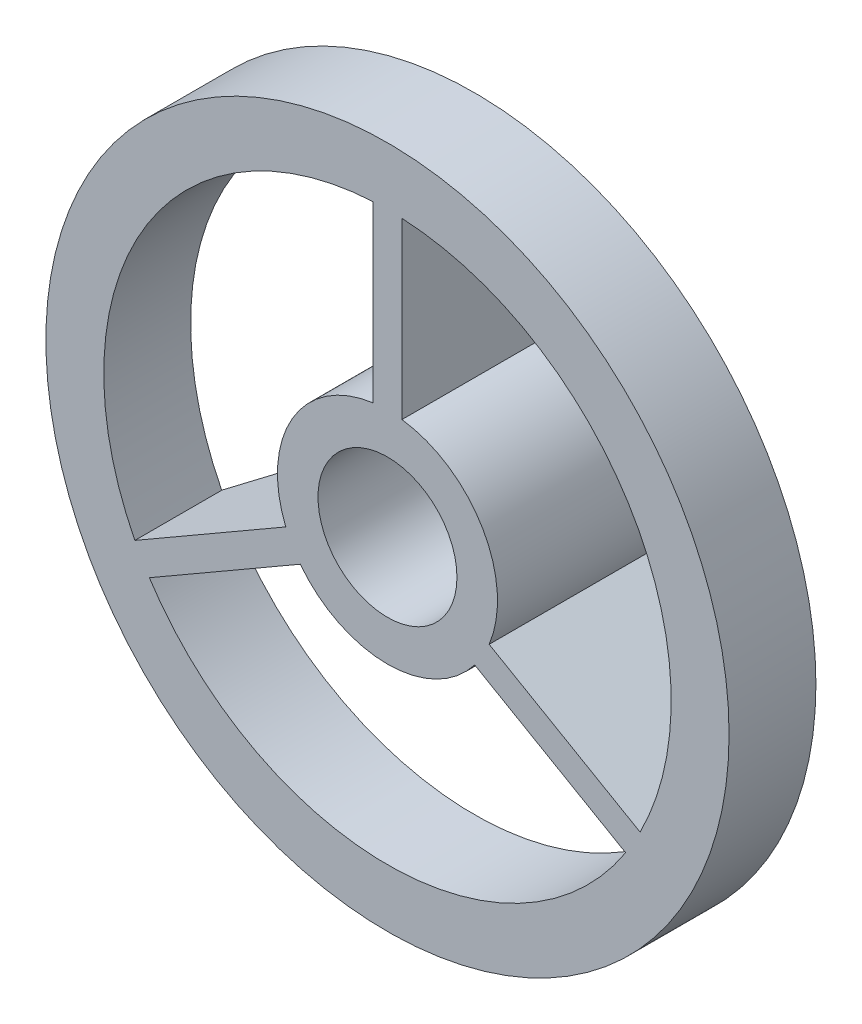
from build123d import *

# Parameters (mm, degrees)
SKETCH1_R           = 1.9
SKETCH1_R_2         = 1.2
BOSS_EXTRUDE1_DEPTH = 3.5
SKETCH2_R           = 5.9
SKETCH2_R_2         = 4.9
BOSS_EXTRUDE2_DEPTH = 1.5
BOSS_EXTRUDE3_DEPTH = 0.25
CIRPATTERN1_COUNT   = 3


with BuildPart() as part:
    # Sketch1 → Boss-Extrude1 (new body)
    with BuildSketch(Plane.XY):
        Circle(SKETCH1_R)
        Circle(SKETCH1_R_2, mode=Mode.SUBTRACT)
    extrude(amount=BOSS_EXTRUDE1_DEPTH)



with BuildPart() as body_2:
    # Sketch2 → Boss-Extrude2 (new body)
    with BuildSketch(Plane.XY.offset(3.5)):
        Circle(SKETCH2_R)
        Circle(SKETCH2_R_2, mode=Mode.SUBTRACT)
    extrude(amount=-BOSS_EXTRUDE2_DEPTH)


with BuildPart() as part_1:
    add(part.part)

    add(body_2.part)  # Boss-Extrude3 merges body 2
    # Sketch3 → Boss-Extrude3 (add, symmetric)
    with BuildSketch(Plane(origin=(0, 0, 0), x_dir=(0, 0, -1), z_dir=(1, 0, 0))):
        Polygon((0, 1.9), (-2, 4.9), (-3.5, 4.9), (-3.5, 1.9), (-3.5, 1.7), (0, 1.7), align=None)
    boss_extrude3 = extrude(amount=BOSS_EXTRUDE3_DEPTH, both=True)

    # CirPattern1: Boss-Extrude3 ×3 about axis
    cirpattern1_axis = Axis((0, 0, 0), (0, 0, 1))
    for i in range(1, CIRPATTERN1_COUNT):
        add(boss_extrude3.rotate(cirpattern1_axis, i * 360 / CIRPATTERN1_COUNT))


solid = part_1.part
